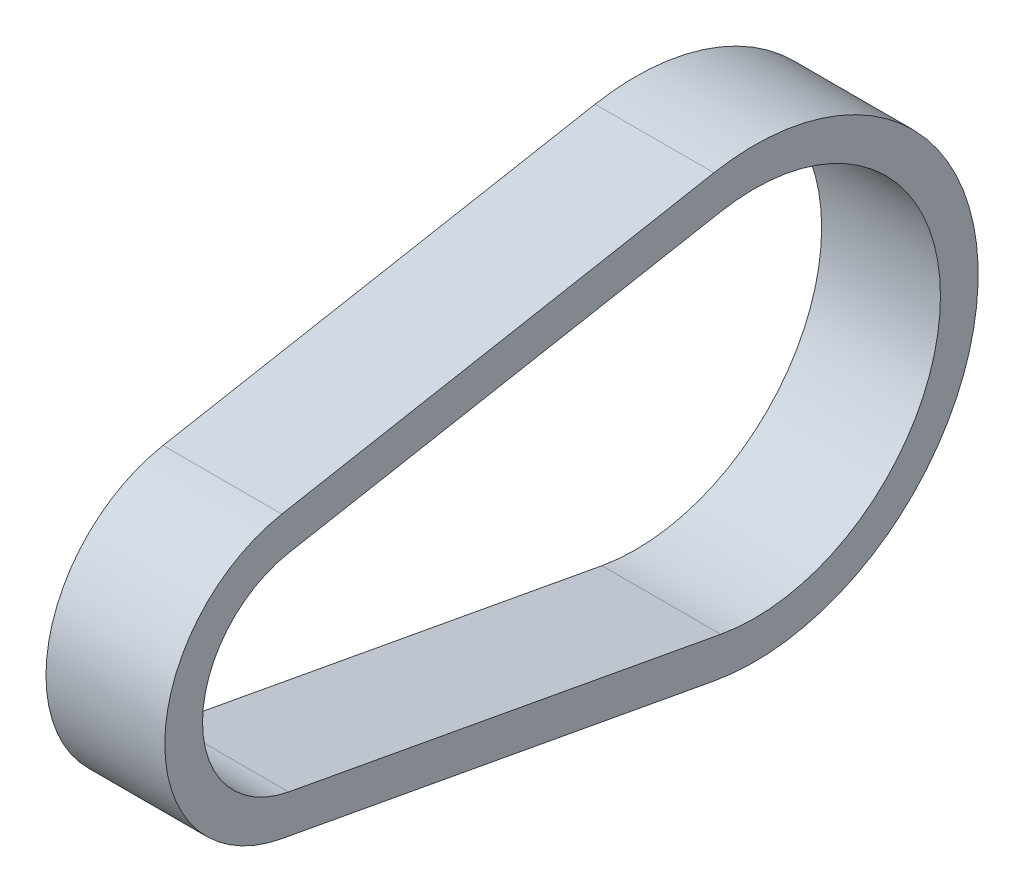
from build123d import *

# Parameters (mm, degrees)
BOSS_EXTRUDE1_DEPTH = 7.5


with BuildPart() as part:
    # Sketch1 → Boss-Extrude1 (new body, symmetric)
    with BuildSketch(Plane(origin=(0, 0, 0), x_dir=(0, 0, -1), z_dir=(1, 0, 0))):
        with BuildLine():
            Line((-3.266661591, 17.748585942), (51.281145188, 27.788215344))
            ThreePointArc((51.281145188, 27.788215344), (84.65058, 0), (51.281145188, -27.788215344))
            Line((51.281145188, -27.788215344), (-3.266661591, -17.748585942))
            ThreePointArc((-3.266661591, -17.748585942), (-18.0467, 0), (-3.266661591, 17.748585942))
        make_face()
        with BuildLine():
            Line((-2.404593965, 13.064757843), (52.143212814, 23.104387245))
            ThreePointArc((52.143212814, 23.104387245), (79.88808, 0), (52.143212814, -23.104387245))
            Line((52.143212814, -23.104387245), (-2.404593965, -13.064757843))
            ThreePointArc((-2.404593965, -13.064757843), (-13.2842, 0), (-2.404593965, 13.064757843))
        make_face(mode=Mode.SUBTRACT)
    extrude(amount=BOSS_EXTRUDE1_DEPTH, both=True)


solid = part.part
